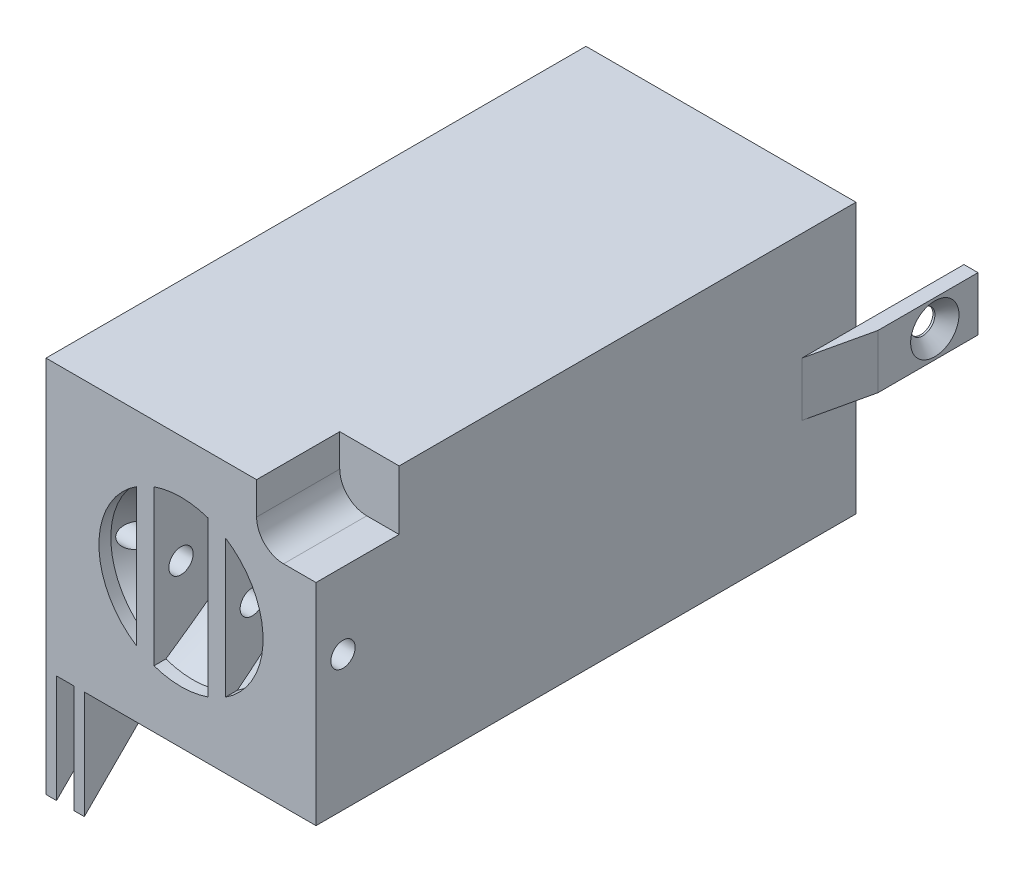
from build123d import *

# Parameters (mm, degrees)
CROQUIS1_W                                           = 50
CROQUIS1_H                                           = 50
CROQUIS1_R                                           = 2
SALIENTE_EXTRUIR2_DEPTH                              = 100
CROQUIS4_W                                           = 3.2
CROQUIS4_H                                           = 40
SALIENTE_EXTRUIR5_DEPTH                              = 10.2
CROQUIS8_R                                           = 4
CORTAR_EXTRUIR3_DEPTH                                = 87.4
CORTAR_EXTRUIR2_START                                = -50
CROQUIS7_R                                           = 2
CORTAR_EXTRUIR2_DEPTH                                = 50
REFRENTADO_PARA_TORNILLO_TAP_N_CON_CABEZ_D           = 4.5
REFRENTADO_PARA_TORNILLO_TAP_N_CON_CABEZ_CSINK_D     = 8.96
REFRENTADO_PARA_TORNILLO_TAP_N_CON_CABEZ_CSINK_ANGLE = 90
SALIENTE_EXTRUIR6_DEPTH                              = 1.95
SALIENTE_EXTRUIR7_START                              = -5.15
SALIENTE_EXTRUIR7_DEPTH                              = 1.95
CORTAR_EXTRUIR4_DEPTH                                = 15.4
SALIENTE_EXTRUIR8_START                              = -25
SALIENTE_EXTRUIR8_DEPTH                              = 5
SALIENTE_EXTRUIR8_DEPTH_BACK                         = 5
CROQUIS15_R                                          = 2.25
CORTAR_EXTRUIR5_DEPTH                                = 2.6
SALIENTE_EXTRUIR9_START                              = -25
SALIENTE_EXTRUIR9_DEPTH                              = 5
SALIENTE_EXTRUIR9_DEPTH_BACK                         = 5
CROQUIS19_R                                          = 2.25
CORTAR_EXTRUIR6_DEPTH                                = 2.6


with BuildPart() as part:
    # Croquis1 → Saliente-Extruir2 (new body)
    with BuildSketch(Plane.XY):
        Rectangle(CROQUIS1_W, CROQUIS1_H)
        Circle(CROQUIS1_R, mode=Mode.SUBTRACT)
    extrude(amount=SALIENTE_EXTRUIR2_DEPTH)

    # Croquis2 → Cortar-Revolución1 (revolve, cut)
    with BuildSketch(Plane(origin=(0, 0, 0), x_dir=(0, 0, -1), z_dir=(1, 0, 0))):
        Polygon((-100, 15.2), (-100, 0), (-89.8, 0), (-89.8, 10), (-97.8, 15.2), align=None)
    revolve(axis=Axis((0, 0, 100), (0, 0, -1)), mode=Mode.SUBTRACT)

    # Croquis4 → Saliente-Extruir5 (add)
    with BuildSketch(Plane.XY.offset(100)):
        with Locations((-6.6, 0)):
            Rectangle(CROQUIS4_W, CROQUIS4_H)
        with Locations((6.6, 0)):
            Rectangle(CROQUIS4_W, CROQUIS4_H)
    extrude(amount=-SALIENTE_EXTRUIR5_DEPTH)

    # Croquis8 → Cortar-Extruir3 (cut)
    with BuildSketch(Plane.XY.offset(89.8)):
        Circle(CROQUIS8_R)
    extrude(amount=-CORTAR_EXTRUIR3_DEPTH, mode=Mode.SUBTRACT)

    # Croquis7 → Cortar-Extruir2 (cut)
    with BuildSketch(Plane.ZY.offset(25).offset(CORTAR_EXTRUIR2_START)):
        with Locations((95, 0)):
            Circle(CROQUIS7_R)
    extrude(amount=CORTAR_EXTRUIR2_DEPTH, mode=Mode.SUBTRACT)

    # Refrentado para tornillo tap_n con cabez (through all)
    with Locations(Plane.ZY.offset(25)):
        with Locations((95, 0)):
            CounterSinkHole(REFRENTADO_PARA_TORNILLO_TAP_N_CON_CABEZ_D / 2, REFRENTADO_PARA_TORNILLO_TAP_N_CON_CABEZ_CSINK_D / 2, counter_sink_angle=REFRENTADO_PARA_TORNILLO_TAP_N_CON_CABEZ_CSINK_ANGLE)

    # Croquis12 → Saliente-Extruir6 (add)
    with BuildSketch(Plane.ZY.offset(25)):
        Polygon((100, -25), (80, -25), (100, -45), align=None)
    extrude(amount=-SALIENTE_EXTRUIR6_DEPTH)

    # Croquis12_2 → Saliente-Extruir7 (add)
    with BuildSketch(Plane.ZY.offset(25).offset(SALIENTE_EXTRUIR7_START)):
        Polygon((100, -25), (80, -25), (100, -45), align=None)
    extrude(amount=-SALIENTE_EXTRUIR7_DEPTH)

    # Croquis13 → Cortar-Extruir4 (cut)
    with BuildSketch(Plane.XY.offset(100)):
        with BuildLine():
            Line((25, 25), (25, 14))
            Line((25, 14), (19, 14))
            ThreePointArc((19, 14), (15.464466094, 15.464466094), (14, 19))
            Line((14, 19), (14, 25))
            Line((14, 25), (25, 25))
        make_face()
    extrude(amount=-CORTAR_EXTRUIR4_DEPTH, mode=Mode.SUBTRACT)

    # Croquis18 → Saliente-Extruir9 (add, two sides)
    with BuildSketch(Plane(origin=(25, 0, 0), x_dir=(0, 0, -1), z_dir=(1, 0, 0)).offset(SALIENTE_EXTRUIR9_START)) as saliente_extruir9_sk:
        Polygon((0, -25), (20, -25), (20, -27.6), (0.681044045, -27.6), (-10, -25), align=None)
    extrude(amount=SALIENTE_EXTRUIR9_DEPTH)
    extrude(saliente_extruir9_sk.sketch, amount=-SALIENTE_EXTRUIR9_DEPTH_BACK)

    # Croquis19 → Cortar-Extruir6 (cut)
    with BuildSketch(Plane.XZ.offset(27.6)):
        with Locations((0, -12)):
            Circle(CROQUIS19_R)
    extrude(amount=-CORTAR_EXTRUIR6_DEPTH, mode=Mode.SUBTRACT)

    # Croquis21 → Refrentado para tornillo tap_n con c 3 (revolve, cut)
    with BuildSketch(Plane(origin=(0, -27.6, -12), x_dir=(0, 0, -1), z_dir=(1, 0, 0))):
        Polygon((0, 0), (0, 52.6), (2.25, 52.6), (2.25, 2.23), (4.48, 0), align=None)
    revolve(axis=Axis((0, -33.95, -12), (0, 1, 0)), mode=Mode.SUBTRACT)


with BuildPart() as body_2:
    # Croquis14 → Saliente-Extruir8 (new body, two sides)
    with BuildSketch(Plane.XZ.offset(25).offset(SALIENTE_EXTRUIR8_START)) as saliente_extruir8_sk:
        Polygon((25, 0), (25, 10), (27.6, -1.469215888), (27.6, -20), (25, -20), align=None)
    extrude(amount=SALIENTE_EXTRUIR8_DEPTH)
    extrude(saliente_extruir8_sk.sketch, amount=-SALIENTE_EXTRUIR8_DEPTH_BACK)

    # Croquis15 → Cortar-Extruir5 (cut)
    with BuildSketch(Plane(origin=(27.6, 0, 0), x_dir=(0, 0, -1), z_dir=(1, 0, 0))):
        with Locations((12, 0)):
            Circle(CROQUIS15_R)
    extrude(amount=-CORTAR_EXTRUIR5_DEPTH, mode=Mode.SUBTRACT)

    # Croquis17 → Refrentado para tornillo tap_n con c 2 (revolve, cut)
    with BuildSketch(Plane(origin=(27.6, 0, -12), x_dir=(0, 0, -1), z_dir=(0, 1, 0))):
        Polygon((0, 0), (0, 52.6), (2.25, 52.6), (2.25, 2.23), (4.48, 0), align=None)
    revolve(axis=Axis((33.95, 0, -12), (-1, 0, 0)), mode=Mode.SUBTRACT)


solid = Compound([part.part, body_2.part])
